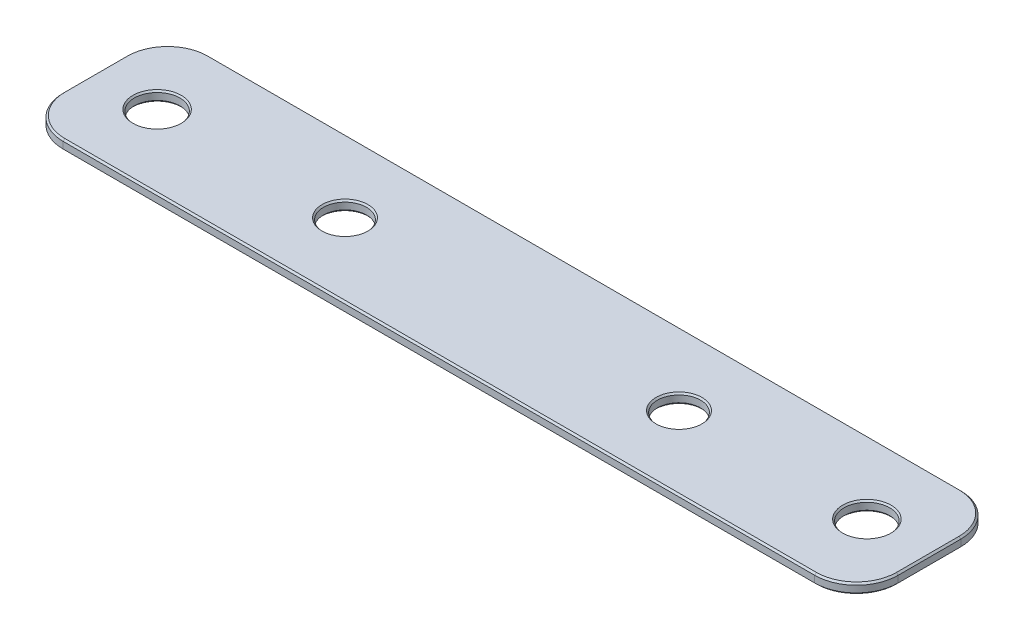
from build123d import *

# Parameters (mm, degrees)
SKETCH1_W                        = 254
SKETCH1_H                        = 44.45
EXTRUDE1_DEPTH                   = 3.048
FILLET1_R                        = 12.7
CHAMFER1_SIZE                    = 0.508
EXTRUDE4_DEPTH                   = 255
F_1_2_CLEARANCE_HOLE4_AT_2_COUNT = 2
F_1_2_CLEARANCE_HOLE4_AT_2_PITCH = 101.6
F_1_2_CLEARANCE_HOLE5_AT_2_COUNT = 2
F_1_2_CLEARANCE_HOLE5_AT_2_PITCH = 215.9


with BuildPart() as part:
    # Sketch1 → Extrude1 (new body)
    with BuildSketch(Plane(origin=(0, 0, 0), x_dir=(1, 0, 0), z_dir=(0, 1, 0))):
        Rectangle(SKETCH1_W, SKETCH1_H)
    extrude(amount=EXTRUDE1_DEPTH)

    # Fillet1
    fillet1_edges = [part.edges().sort_by_distance(p)[0] for p in [
        (-127, 1.524, -22.225),
        (127, 1.524, -22.225),
        (127, 1.524, 22.225),
        (-127, 1.524, 22.225),
    ]]
    fillet(fillet1_edges, radius=FILLET1_R)

    # Chamfer1
    chamfer1_edges = [part.edges().sort_by_distance(p)[0] for p in [
        (0, 0, 22.225),
        (0, 3.048, 22.225),
        (-127, 0, 0),
        (0, 0, -22.225),
        (127, 0, 0),
        (-123.280256121, 0, -18.505256121),
        (123.280256121, 0, -18.505256121),
        (123.280256121, 0, 18.505256121),
        (-123.280256121, 0, 18.505256121),
        (-127, 3.048, 0),
        (127, 3.048, 0),
        (0, 3.048, -22.225),
        (-123.280256121, 3.048, -18.505256121),
        (123.280256121, 3.048, -18.505256121),
        (123.280256121, 3.048, 18.505256121),
        (-123.280256121, 3.048, 18.505256121),
    ]]
    chamfer(chamfer1_edges, length=CHAMFER1_SIZE)

    # Sketch9 → Extrude4 (cut, through all)
    with BuildSketch(Plane(origin=(127, 0, 0), x_dir=(0, 0, -1), z_dir=(1, 0, 0))):
        with BuildLine():
            Line((-1.778, 0), (1.778, 0))
            ThreePointArc((1.778, 0), (0, 0.254), (-1.778, 0))
        make_face()
    extrude(amount=-EXTRUDE4_DEPTH, mode=Mode.SUBTRACT)

    # Sketch10 → 1/2 Clearance Hole4 (revolve, cut)
    with BuildSketch(Plane(origin=(-50.8, 3.048, 0), x_dir=(0, 0, 1), z_dir=(1, 0, 0))):
        Polygon((0, 0), (0, 3.048), (6.985, 3.048), (6.54812, 2.54542705), (6.54812, 0.50257295), (6.985, 0), align=None)
    f_1_2_clearance_hole4 = revolve(axis=Axis((-50.8, 9.398, 0), (0, -1, 0)), mode=Mode.SUBTRACT)

    # 1/2 Clearance Hole4 at 2: 1/2 Clearance Hole4 ×2
    with Locations(*[(i * F_1_2_CLEARANCE_HOLE4_AT_2_PITCH, 0, 0) for i in range(1, F_1_2_CLEARANCE_HOLE4_AT_2_COUNT)]):
        add(f_1_2_clearance_hole4, mode=Mode.SUBTRACT)

    # Sketch12 → 1/2 Clearance Hole5 (revolve, cut)
    with BuildSketch(Plane(origin=(-107.95, 3.048, 0), x_dir=(0, 0, 1), z_dir=(1, 0, 0))):
        Polygon((0, 0), (0, 3.048), (7.366, 3.048), (6.94563, 2.564419633), (6.94563, 0.483580367), (7.366, 0), align=None)
    f_1_2_clearance_hole5 = revolve(axis=Axis((-107.95, 9.398, 0), (0, -1, 0)), mode=Mode.SUBTRACT)

    # 1/2 Clearance Hole5 at 2: 1/2 Clearance Hole5 ×2
    with Locations(*[(i * F_1_2_CLEARANCE_HOLE5_AT_2_PITCH, 0, 0) for i in range(1, F_1_2_CLEARANCE_HOLE5_AT_2_COUNT)]):
        add(f_1_2_clearance_hole5, mode=Mode.SUBTRACT)


solid = part.part
